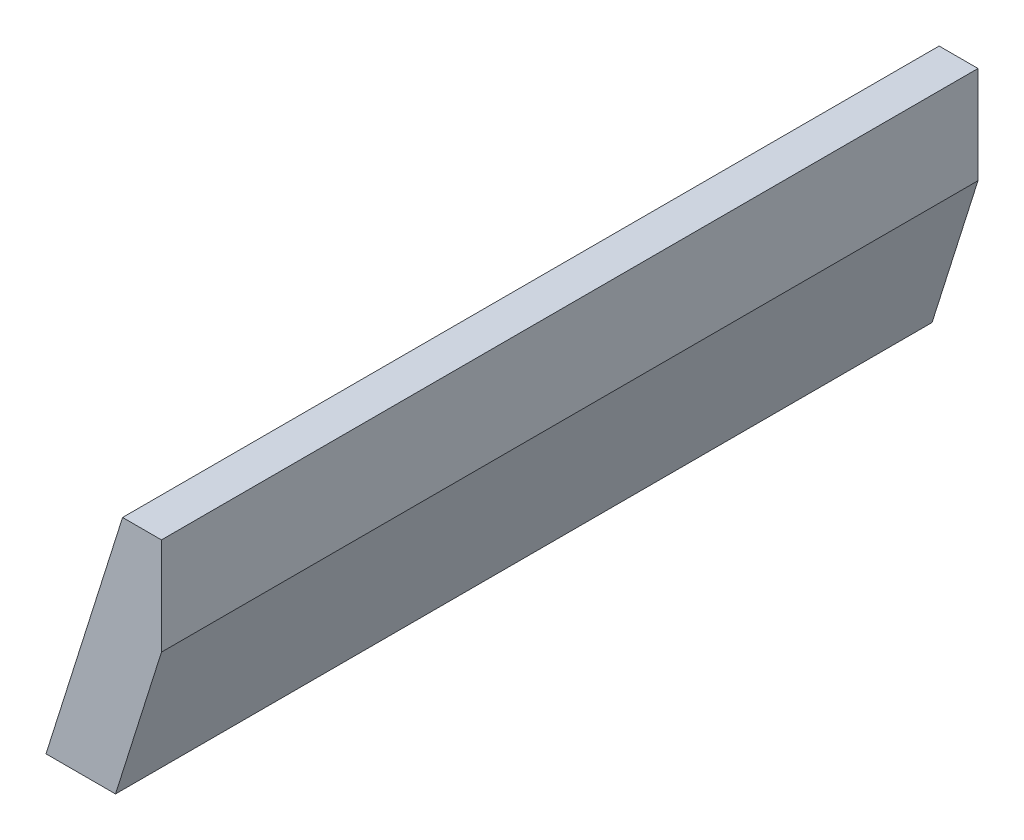
from build123d import *

# Parameters (mm, degrees)
BOSS_EXTRUDE1_DEPTH = 42


with BuildPart() as part:
    # Sketch1 → Boss-Extrude1 (new body, symmetric)
    with BuildSketch(Plane.XY):
        Polygon((5.444559644, 11.949484432), (5.444559644, 1.949484432), (0.71795591, -13.050515568), (-6.433113246, -13.050515568), (1.444559644, 11.949484432), align=None)
    extrude(amount=BOSS_EXTRUDE1_DEPTH, both=True)


solid = part.part
